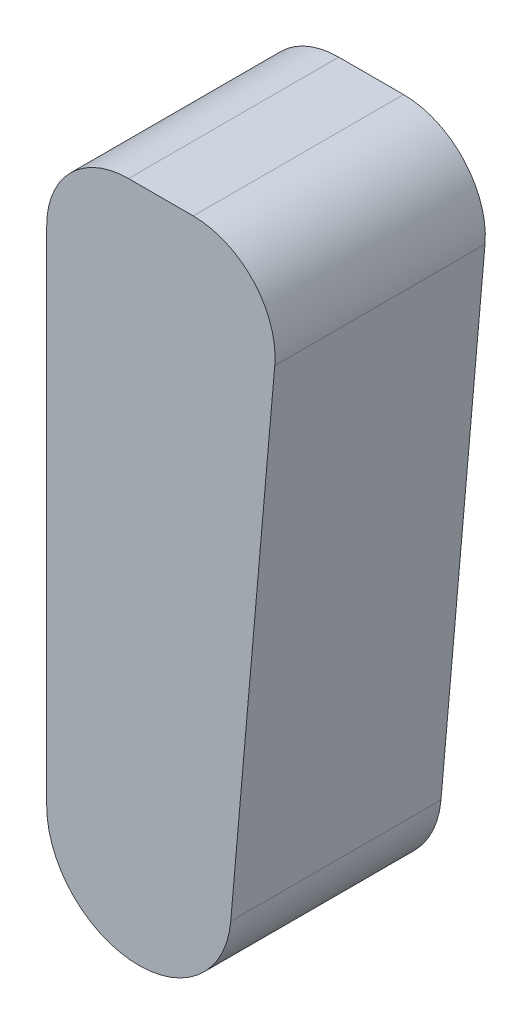
from build123d import *

# Parameters (mm, degrees)
BOSS_EXTRU_1_DEPTH = 18
CONG_1_R           = 7


with BuildPart() as part:
    # Esquisse2 → Boss.-Extru.1 (new body)
    with BuildSketch(Plane.XY):
        with BuildLine():
            Line((-7.891319926, 50), (12.295896662, 50))
            Line((12.295896662, 50), (7.861291071, -0.687773849))
            ThreePointArc((7.861291071, -0.687773849), (-0.344214541, -7.883809138), (-7.891319926, 0))
            Line((-7.891319926, 0), (-7.891319926, 50))
        make_face()
    extrude(amount=BOSS_EXTRU_1_DEPTH)

    # Congé1
    cong_1_edges = [part.edges().sort_by_distance(p)[0] for p in [
        (-7.891319926, 50, 9),
        (12.295896662, 50, 9),
    ]]
    fillet(cong_1_edges, radius=CONG_1_R)


solid = part.part
